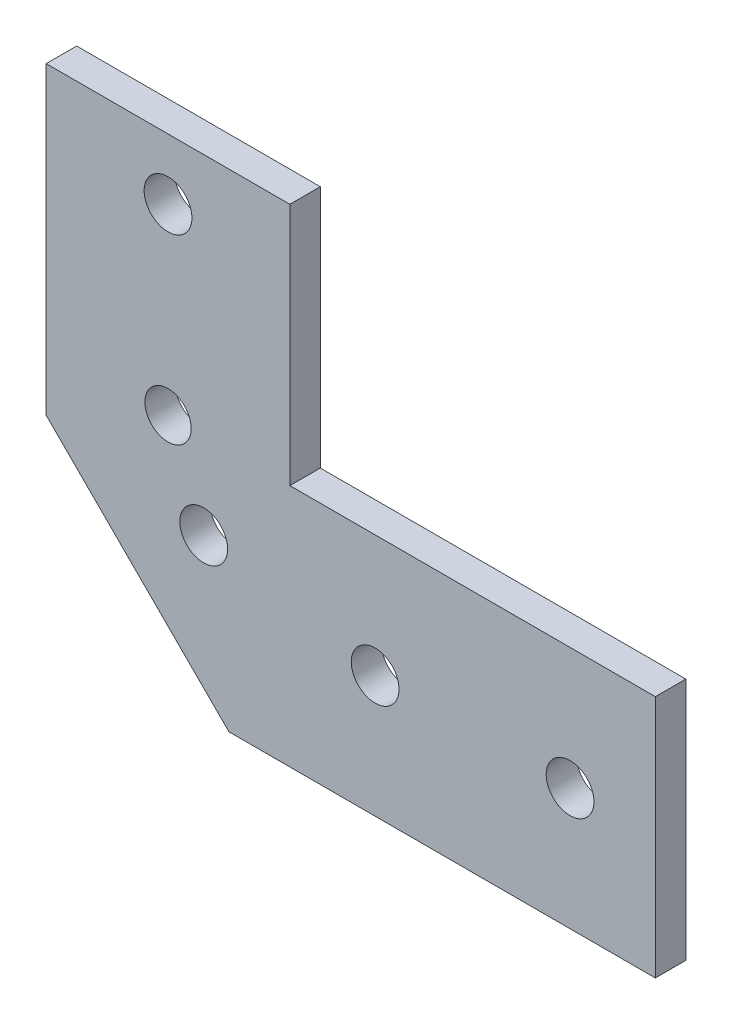
from build123d import *

# Parameters (mm, degrees)
BOSS_EXTRUDE1_DEPTH = 3.175
SKETCH3_R           = 2.4892
CUT_EXTRUDE1_DEPTH  = 4.175
SKETCH4_R           = 2.413
CUT_EXTRUDE2_DEPTH  = 4.175
SKETCH5_W           = 25.4
SKETCH5_H           = 12.7
CUT_EXTRUDE3_DEPTH  = 4.175


with BuildPart() as part:
    # Sketch2 → Boss-Extrude1 (new body)
    with BuildSketch(Plane.XY):
        Polygon((0, 0), (0, 63.5), (25.4, 63.5), (25.4, 25.4), (63.5, 25.4), (63.5, 0), align=None)
    extrude(amount=BOSS_EXTRUDE1_DEPTH)

    # Sketch3 → Cut-Extrude1 (cut, through all)
    with BuildSketch(Plane.XY.offset(3.175)):
        with Locations((16.419743879, 16.419743879)):
            Circle(SKETCH3_R)
        with Locations((12.7, 54.61)):
            Circle(SKETCH3_R)
        with Locations((12.7, 44.45)):
            Circle(SKETCH3_R)
        with Locations((34.29, 12.7)):
            Circle(SKETCH3_R)
        with Locations((54.61, 12.7)):
            Circle(SKETCH3_R)
        Polygon((0, 0), (0, 19.05), (19.05, 0), align=None)
    extrude(amount=-CUT_EXTRUDE1_DEPTH, mode=Mode.SUBTRACT)

    # Sketch4 → Cut-Extrude2 (cut, through all)
    with BuildSketch(Plane(origin=(0, 0, 0), x_dir=(-1, 0, 0), z_dir=(0, 0, -1))):
        with Locations((-12.7, 25.4)):
            Circle(SKETCH4_R)
    extrude(amount=-CUT_EXTRUDE2_DEPTH, mode=Mode.SUBTRACT)

    # Sketch5 → Cut-Extrude3 (cut, through all)
    with BuildSketch(Plane.XY.offset(3.175)):
        with Locations((12.7, 57.15)):
            Rectangle(SKETCH5_W, SKETCH5_H)
    extrude(amount=-CUT_EXTRUDE3_DEPTH, mode=Mode.SUBTRACT)


solid = part.part
